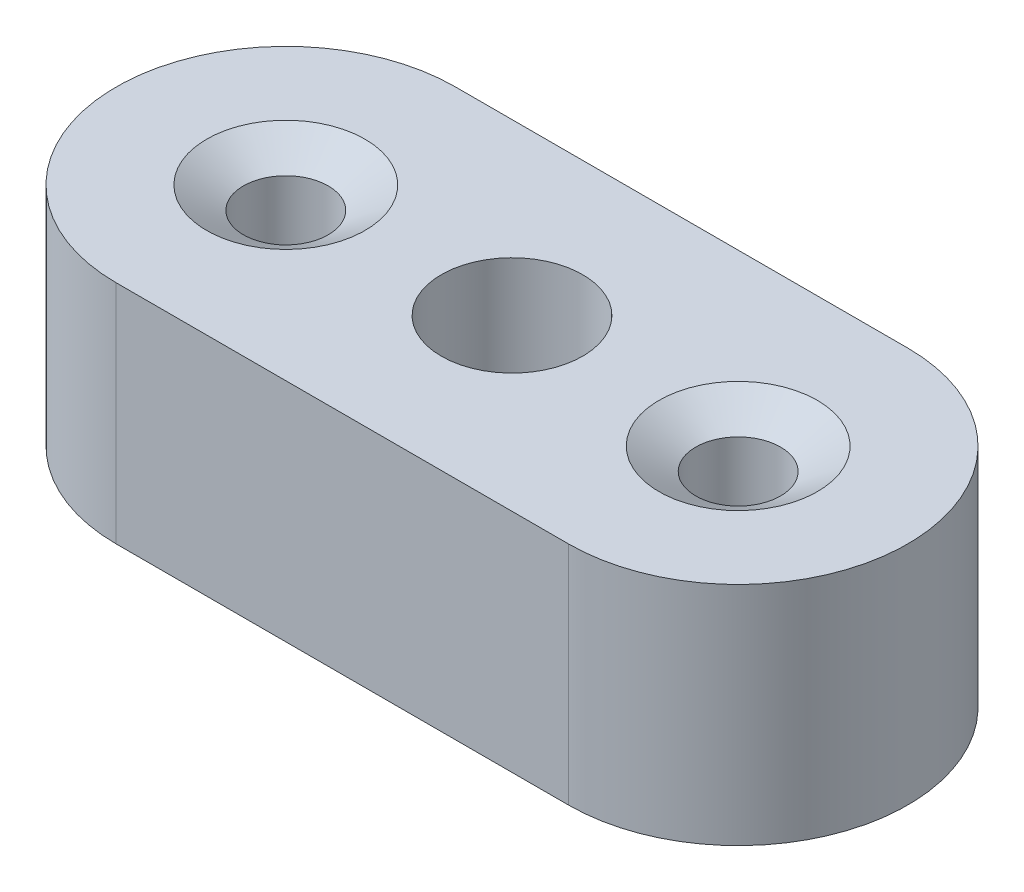
from build123d import *

# Parameters (mm, degrees)
SKETCH1_R           = 3.96875
BOSS_EXTRUDE1_DEPTH = 12.7


with BuildPart() as part:
    # Sketch1 → Boss-Extrude1 (new body)
    with BuildSketch(Plane(origin=(0, 0, 0), x_dir=(1, 0, 0), z_dir=(0, 1, 0))):
        with BuildLine():
            Line((-12.7, 9.525), (12.7, 9.525))
            ThreePointArc((12.7, 9.525), (22.225, 0), (12.7, -9.525))
            Line((12.7, -9.525), (-12.7, -9.525))
            ThreePointArc((-12.7, -9.525), (-22.225, 0), (-12.7, 9.525))
        make_face()
        Circle(SKETCH1_R, mode=Mode.SUBTRACT)
    extrude(amount=BOSS_EXTRUDE1_DEPTH)

    # Sketch2 → Cut-Revolve1 (revolve, cut)
    with BuildSketch(Plane.XY):
        Polygon((-12.7, 12.7), (-17.145, 12.7), (-15.08125, 11.459973897), (-15.08125, 0), (-12.7, 0), align=None)
    cut_revolve1 = revolve(axis=Axis((-12.7, 0, 0), (0, 1, 0)), mode=Mode.SUBTRACT)

    # Mirror1: Cut-Revolve1 across plane
    add(cut_revolve1.mirror(Plane(origin=(0, 0, 0), x_dir=(0, 0, 1), z_dir=(1, 0, 0))), mode=Mode.SUBTRACT)


solid = part.part
